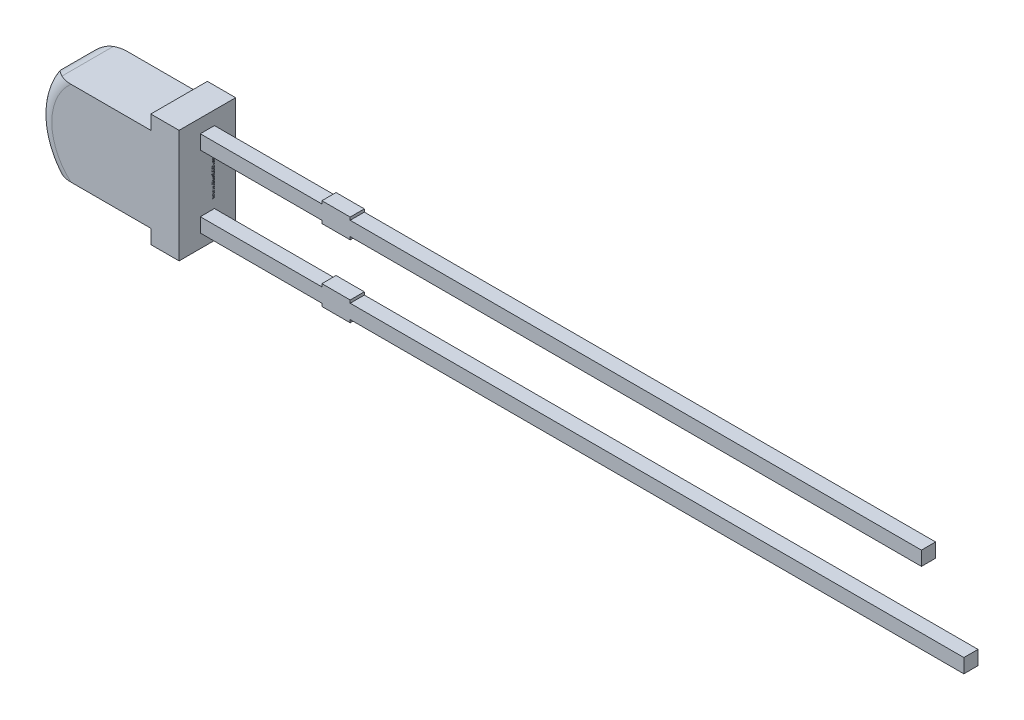
from build123d import *

# Parameters (mm, degrees)
SKETCH1_W          = 25.5
SKETCH1_H          = 0.5
SKETCH1_W_2        = 27
SKETCH1_W_3        = 1
SKETCH1_H_2        = 0.7
EXTRUDE2_DEPTH     = 0.25
EXTRUDE3_DEPTH     = 1
FILLET1_R          = 0.5
SKETCH2_W          = 0.026582278
SKETCH2_H          = 0.025316456
CUT_EXTRUDE1_DEPTH = 0.01


with BuildPart() as part:
    # Sketch1 → Extrude2 (new body, symmetric)
    with BuildSketch(Plane.XY):
        with Locations((15, 1.27)):
            Rectangle(SKETCH1_W, SKETCH1_H)
        with Locations((15.75, -1.27)):
            Rectangle(SKETCH1_W_2, SKETCH1_H)
        with Locations((7.05, 1.27)):
            Rectangle(SKETCH1_W_3, SKETCH1_H_2)
        with Locations((7.05, -1.27)):
            Rectangle(SKETCH1_W_3, SKETCH1_H_2)
    extrude(amount=EXTRUDE2_DEPTH, both=True)

    # Sketch1_5 → Extrude3 (add, symmetric)
    with BuildSketch(Plane.XY):
        with BuildLine():
            Line((1.25, 1.5), (-2.25, 1.5))
            ThreePointArc((-2.25, 1.5), (-2.75, 0), (-2.25, -1.5))
            Line((-2.25, -1.5), (1.25, -1.5))
            Line((1.25, -1.5), (1.25, -2))
            Line((1.25, -2), (2.25, -2))
            Line((2.25, -2), (2.25, 2))
            Line((2.25, 2), (1.25, 2))
            Line((1.25, 2), (1.25, 1.5))
        make_face()
    extrude(amount=EXTRUDE3_DEPTH, both=True)

    # Fillet1
    fillet1_edges = [part.edges().sort_by_distance(p)[0] for p in [
        (-2.25, -1.5, 0),
        (-2.75, 0, 1),
        (-2.25, 1.5, 0),
        (-2.75, 0, -1),
    ]]
    fillet(fillet1_edges, radius=FILLET1_R)

    # Sketch2 → Cut-Extrude1 (cut)
    with BuildSketch(Plane(origin=(2.25, 0, 0), x_dir=(0, 0, -1), z_dir=(1, 0, 0))):
        Polygon((0.175316456, -0.572151899), (0.25, -0.595609177), (0.25, -0.620352057), (0.199663766, -0.636768196), (0.25, -0.652294304), (0.25, -0.678026108), (0.175316456, -0.701265823), (0.175316456, -0.676087816), (0.226799842, -0.663093354), (0.175316456, -0.646677215), (0.175316456, -0.625178006), (0.226799842, -0.608860759), (0.175316456, -0.596044304), align=None)
        Polygon((0.175316456, -0.437974684), (0.25, -0.461431962), (0.25, -0.486174842), (0.199663766, -0.502590981), (0.25, -0.518117089), (0.25, -0.543848892), (0.175316456, -0.567088608), (0.175316456, -0.541910601), (0.226799842, -0.528916139), (0.175316456, -0.5125), (0.175316456, -0.491000791), (0.226799842, -0.474683544), (0.175316456, -0.461867089), align=None)
        Polygon((0.175316456, -0.303797468), (0.25, -0.327254747), (0.25, -0.351997627), (0.199663766, -0.368413766), (0.25, -0.383939873), (0.25, -0.409671677), (0.175316456, -0.432911392), (0.175316456, -0.407733386), (0.226799842, -0.394738924), (0.175316456, -0.378322785), (0.175316456, -0.356823576), (0.226799842, -0.340506329), (0.175316456, -0.327689873), align=None)
        with Locations((0.236708861, -0.275949367)):
            Rectangle(SKETCH2_W, SKETCH2_H)
        with BuildLine():
            add(Edge.make_bspline(
                [(0.218829114, -0.159493671), (0.220051236, -0.15953019), (0.222451075, -0.159601901), (0.225958932, -0.160211194), (0.229282615, -0.161206237), (0.232443853, -0.162572352), (0.23540828, -0.164381718), (0.238204295, -0.166563022), (0.240818493, -0.169150529), (0.24322702, -0.17210691), (0.245431684, -0.175388005), (0.24732279, -0.178990487), (0.248949325, -0.182859482), (0.2502805, -0.187013878), (0.251271415, -0.191459348), (0.25199469, -0.196177156), (0.252468209, -0.201170496), (0.252510149, -0.204594085), (0.252531646, -0.206348892)],
                knots=[0, 0, 0, 0, 0.907462679, 1.781953809, 2.635804048, 3.480274448, 4.332887508, 5.208817748, 6.109340518, 7.059474472, 8.037577805, 9.041105121, 10.077237313, 11.152245627, 12.27748741, 13.457227022, 14.696666784, 16, 16, 16, 16], degree=3))
            add(Edge.make_bspline(
                [(0.252531646, -0.206348892), (0.252504381, -0.208366877), (0.252451577, -0.212275063), (0.252066204, -0.217942631), (0.251378254, -0.223206098), (0.250421674, -0.228103845), (0.249218389, -0.232708145), (0.247927745, -0.23714149), (0.246463164, -0.241422782), (0.245363028, -0.244195874), (0.244818038, -0.24556962)],
                knots=[0, 0, 0, 0, 1.203182053, 2.33017619, 3.384818652, 4.366208123, 5.30340534, 6.221361684, 7.118890722, 8, 8, 8, 8], degree=3))
            Line((0.244818038, -0.24556962), (0.220886076, -0.24556962))
            Line((0.220886076, -0.24556962), (0.220886076, -0.242721519))
            add(Edge.make_bspline(
                [(0.220886076, -0.242721519), (0.221967039, -0.241355956), (0.224122618, -0.238632846), (0.226890972, -0.234205888), (0.229263982, -0.229546876), (0.231246605, -0.224708482), (0.232822219, -0.219807114), (0.233949125, -0.214938046), (0.234688489, -0.210169064), (0.23477005, -0.207010742), (0.234810127, -0.205458861)],
                knots=[0, 0, 0, 0, 1.030738938, 2.055426519, 3.085610749, 4.123842265, 5.148648843, 6.130724483, 7.081507926, 8, 8, 8, 8], degree=3))
            add(Edge.make_bspline(
                [(0.234810127, -0.205458861), (0.23480879, -0.205030118), (0.234805929, -0.204112212), (0.234685817, -0.202649556), (0.234555416, -0.201000033), (0.234361419, -0.199225642), (0.234127047, -0.197432474), (0.233785865, -0.195764575), (0.233413757, -0.194257809), (0.233046659, -0.193351105), (0.232871835, -0.192919304)],
                knots=[0, 0, 0, 0, 0.806557331, 1.726776592, 2.760222249, 3.920734434, 5.085813889, 6.161303184, 7.124353598, 8, 8, 8, 8], degree=3))
            add(Edge.make_bspline(
                [(0.232871835, -0.192919304), (0.232643282, -0.192440047), (0.232194127, -0.191498205), (0.231387464, -0.190196887), (0.230480651, -0.189041565), (0.229519264, -0.18798482), (0.228368617, -0.187098496), (0.226961414, -0.186481634), (0.225313428, -0.186135268), (0.22413807, -0.186096466), (0.223516614, -0.186075949)],
                knots=[0, 0, 0, 0, 1.025060442, 2.01446193, 2.949256246, 3.85908539, 4.768290539, 5.73153362, 6.800575992, 8, 8, 8, 8], degree=3))
            add(Edge.make_bspline(
                [(0.223516614, -0.186075949), (0.222971006, -0.186107814), (0.221898181, -0.186170468), (0.220362632, -0.186747374), (0.21895522, -0.187657973), (0.217681809, -0.188931946), (0.216563537, -0.190544736), (0.215540893, -0.192462318), (0.21471198, -0.194733369), (0.214273386, -0.196370181), (0.214042722, -0.197231013)],
                knots=[0, 0, 0, 0, 0.825786558, 1.623739628, 2.456775365, 3.355767579, 4.339087636, 5.42728423, 6.646958453, 8, 8, 8, 8], degree=3))
            add(Edge.make_bspline(
                [(0.214042722, -0.197231013), (0.213597012, -0.199200151), (0.212682272, -0.203241458), (0.211503178, -0.209382993), (0.210268525, -0.21551983), (0.209057108, -0.219470134), (0.20846519, -0.221400316)],
                knots=[0, 0, 0, 0, 0.976116373, 2.003306214, 3.02438349, 4, 4, 4, 4], degree=3))
            add(Edge.make_bspline(
                [(0.20846519, -0.221400316), (0.20811147, -0.222438472), (0.20742292, -0.224459338), (0.206270237, -0.227358497), (0.204965225, -0.23000186), (0.203642765, -0.232459004), (0.202164164, -0.234653033), (0.200623419, -0.236646745), (0.198984461, -0.238419051), (0.197227076, -0.239944561), (0.195392008, -0.241289007), (0.193443793, -0.242440034), (0.191382477, -0.243408151), (0.18921802, -0.244200582), (0.18694876, -0.244819413), (0.18457149, -0.245239559), (0.182088239, -0.245538255), (0.180393871, -0.245559023), (0.179529272, -0.24556962)],
                knots=[0, 0, 0, 0, 1.287139616, 2.505537848, 3.65787682, 4.745319116, 5.777517297, 6.75878323, 7.700384896, 8.605120322, 9.485712598, 10.366814604, 11.256335458, 12.154696155, 13.068779358, 14.012730507, 14.985940713, 16, 16, 16, 16], degree=3))
            add(Edge.make_bspline(
                [(0.179529272, -0.24556962), (0.178373126, -0.24553232), (0.176097851, -0.245458913), (0.172768828, -0.244857463), (0.16962001, -0.243830953), (0.166616854, -0.242444593), (0.16380259, -0.2406171), (0.161125104, -0.238424977), (0.158632608, -0.235814667), (0.156333971, -0.23282934), (0.154255166, -0.229542493), (0.152418458, -0.226008488), (0.150912011, -0.222229636), (0.14963078, -0.218249751), (0.148678384, -0.214030359), (0.147958807, -0.209593388), (0.147545806, -0.204919526), (0.147494531, -0.201728115), (0.147468354, -0.200098892)],
                knots=[0, 0, 0, 0, 0.894901293, 1.761149761, 2.608783409, 3.453876344, 4.314933854, 5.200038827, 6.12799933, 7.103249695, 8.113098521, 9.136064399, 10.182719798, 11.259667356, 12.370545059, 13.528828137, 14.738461593, 16, 16, 16, 16], degree=3))
            add(Edge.make_bspline(
                [(0.147468354, -0.200098892), (0.147490709, -0.198430234), (0.14753538, -0.195095747), (0.147910922, -0.190113874), (0.14847452, -0.185162543), (0.149281503, -0.180292383), (0.150290966, -0.17560825), (0.151380413, -0.171185772), (0.152620339, -0.167106707), (0.153574441, -0.164532994), (0.15403481, -0.163291139)],
                knots=[0, 0, 0, 0, 1.065384654, 2.128962885, 3.18847586, 4.246683315, 5.279600907, 6.247539799, 7.154412252, 8, 8, 8, 8], degree=3))
            Line((0.15403481, -0.163291139), (0.176582278, -0.163291139))
            Line((0.176582278, -0.163291139), (0.176582278, -0.166119462))
            add(Edge.make_bspline(
                [(0.176582278, -0.166119462), (0.175783133, -0.16719302), (0.174152259, -0.16938391), (0.172048226, -0.173032632), (0.170116523, -0.177006091), (0.168387193, -0.181273774), (0.166968062, -0.185747065), (0.165938626, -0.190324411), (0.165299605, -0.194951528), (0.165226459, -0.198053112), (0.165189873, -0.19960443)],
                knots=[0, 0, 0, 0, 0.892231706, 1.82084296, 2.804411717, 3.838445872, 4.890103822, 5.931567007, 6.965432763, 8, 8, 8, 8], degree=3))
            add(Edge.make_bspline(
                [(0.165189873, -0.19960443), (0.165214522, -0.200699669), (0.165263948, -0.202895847), (0.165607428, -0.206171246), (0.166287131, -0.209404419), (0.167098237, -0.211441491), (0.167503956, -0.212460443)],
                knots=[0, 0, 0, 0, 0.99896713, 2.003134239, 3.001159596, 4, 4, 4, 4], degree=3))
            add(Edge.make_bspline(
                [(0.167503956, -0.212460443), (0.16770515, -0.212894149), (0.168107405, -0.21376127), (0.168886797, -0.214969172), (0.169804037, -0.216088766), (0.170857301, -0.217093311), (0.172038369, -0.217917451), (0.17330104, -0.218558729), (0.174663973, -0.218918158), (0.175598013, -0.218964182), (0.176068038, -0.218987342)],
                knots=[0, 0, 0, 0, 1.005120364, 2.009570296, 3.014977851, 4.045438181, 5.061509448, 6.035608779, 7.011484765, 8, 8, 8, 8], degree=3))
            add(Edge.make_bspline(
                [(0.176068038, -0.218987342), (0.176705969, -0.218952547), (0.177924997, -0.218886059), (0.179638693, -0.218286061), (0.181101805, -0.217288392), (0.182094798, -0.216135293), (0.182793558, -0.215018314), (0.183298798, -0.213977797), (0.183812221, -0.212778346), (0.184301418, -0.211400897), (0.184795464, -0.209865762), (0.185270134, -0.20815684), (0.185719693, -0.206274232), (0.186005845, -0.204958342), (0.186155063, -0.204272152)],
                knots=[0, 0, 0, 0, 1.174343879, 2.244064321, 3.303704314, 4.407076671, 5.02483983, 5.732197225, 6.53898402, 7.431906431, 8.428480183, 9.514816237, 10.704066255, 12, 12, 12, 12], degree=3))
            add(Edge.make_bspline(
                [(0.186155063, -0.204272152), (0.186531164, -0.202439393), (0.187268822, -0.198844747), (0.188372053, -0.193441658), (0.189674916, -0.187946356), (0.190807308, -0.184269987), (0.191396361, -0.182357595)],
                knots=[0, 0, 0, 0, 0.995794372, 1.953081347, 2.935223864, 4, 4, 4, 4], degree=3))
            add(Edge.make_bspline(
                [(0.191396361, -0.182357595), (0.191715717, -0.181411104), (0.19234043, -0.179559616), (0.19342515, -0.176918101), (0.194607113, -0.174468933), (0.195830039, -0.172191063), (0.197191731, -0.170127593), (0.198609062, -0.168242758), (0.200115036, -0.166545595), (0.201730389, -0.165056465), (0.203441066, -0.163728463), (0.205290718, -0.162613457), (0.207239881, -0.161626842), (0.209320315, -0.160835225), (0.211531277, -0.160250746), (0.213858161, -0.159818068), (0.216303313, -0.159526859), (0.217977782, -0.159504857), (0.218829114, -0.159493671)],
                knots=[0, 0, 0, 0, 1.237247399, 2.420255609, 3.534416354, 4.605351393, 5.620193117, 6.593738998, 7.524982051, 8.426564095, 9.311945829, 10.20281032, 11.097671666, 12.01534975, 12.954438892, 13.926750701, 14.945921247, 16, 16, 16, 16], degree=3))
        make_face()
        with BuildLine():
            Line((0.25, -0.067088608), (0.25, -0.091139241))
            Line((0.25, -0.091139241), (0.242167722, -0.091139241))
            add(Edge.make_bspline(
                [(0.242167722, -0.091139241), (0.242976625, -0.092232381), (0.244536179, -0.094339941), (0.246611792, -0.097515206), (0.248404118, -0.100536174), (0.249910142, -0.103474602), (0.251137796, -0.106474005), (0.251949951, -0.109708164), (0.252454032, -0.113209191), (0.2525052, -0.115636342), (0.252531646, -0.116890823)],
                knots=[0, 0, 0, 0, 1.15097647, 2.219065785, 3.209751872, 4.123278731, 5.012494873, 5.946522673, 6.938654008, 8, 8, 8, 8], degree=3))
            add(Edge.make_bspline(
                [(0.252531646, -0.116890823), (0.252508688, -0.117907091), (0.252463982, -0.11988606), (0.2521224, -0.122764448), (0.2515735, -0.125466099), (0.250806818, -0.127996041), (0.249795405, -0.130347067), (0.248544706, -0.132504746), (0.247082839, -0.134491413), (0.245406585, -0.136295066), (0.243485438, -0.137885611), (0.241362738, -0.139272682), (0.239028085, -0.140448488), (0.236476722, -0.141390128), (0.233718277, -0.142145061), (0.230739071, -0.142669038), (0.227551931, -0.142989618), (0.225356803, -0.143021559), (0.224228639, -0.143037975)],
                knots=[0, 0, 0, 0, 1.108887696, 2.159324556, 3.158383213, 4.114277414, 5.039206009, 5.945047284, 6.830075132, 7.726032535, 8.625162295, 9.545152215, 10.487958828, 11.471559655, 12.508379831, 13.604991163, 14.769110247, 16, 16, 16, 16], degree=3))
            Line((0.224228639, -0.143037975), (0.175316456, -0.143037975))
            Line((0.175316456, -0.143037975), (0.175316456, -0.118987342))
            Line((0.175316456, -0.118987342), (0.21289557, -0.118987342))
            add(Edge.make_bspline(
                [(0.21289557, -0.118987342), (0.213812041, -0.118985706), (0.215566256, -0.118982576), (0.218072063, -0.118900237), (0.220340235, -0.118779336), (0.222382264, -0.118640631), (0.224229015, -0.118387615), (0.225895176, -0.118009906), (0.227414778, -0.11753908), (0.228321479, -0.117074761), (0.228757911, -0.116851266)],
                knots=[0, 0, 0, 0, 1.361401701, 2.605856924, 3.723918663, 4.735739235, 5.645738665, 6.489217889, 7.27279937, 8, 8, 8, 8], degree=3))
            add(Edge.make_bspline(
                [(0.228757911, -0.116851266), (0.22915655, -0.116621224), (0.229940239, -0.116168982), (0.23094752, -0.115249197), (0.231783912, -0.114173114), (0.232458611, -0.112903872), (0.232933771, -0.111407752), (0.233320951, -0.109682844), (0.233491169, -0.107690452), (0.23352591, -0.106283083), (0.233544304, -0.105537975)],
                knots=[0, 0, 0, 0, 0.848923305, 1.668910138, 2.502822694, 3.358979167, 4.311113223, 5.396624103, 6.621686681, 8, 8, 8, 8], degree=3))
            add(Edge.make_bspline(
                [(0.233544304, -0.105537975), (0.233524355, -0.104997054), (0.233483369, -0.103885683), (0.233294338, -0.102174294), (0.232890178, -0.100392654), (0.232246209, -0.097874301), (0.231059246, -0.094699608), (0.229701719, -0.092335231), (0.229015032, -0.091139241)],
                knots=[0, 0, 0, 0, 0.638098464, 1.31103257, 2.025970928, 2.789492669, 4.376004971, 6, 6, 6, 6], degree=3))
            Line((0.229015032, -0.091139241), (0.175316456, -0.091139241))
            Line((0.175316456, -0.091139241), (0.175316456, -0.067088608))
            Line((0.175316456, -0.067088608), (0.25, -0.067088608))
        make_face()
        with BuildLine():
            Line((0.25, 0.030379747), (0.25, 0.006329114))
            Line((0.25, 0.006329114), (0.212420886, 0.006329114))
            add(Edge.make_bspline(
                [(0.212420886, 0.006329114), (0.210890463, 0.006308303), (0.20783158, 0.006266709), (0.204074178, 0.005938503), (0.201227102, 0.005599031), (0.199397351, 0.005224273), (0.197849034, 0.004793931), (0.196963295, 0.004381503), (0.196558544, 0.004193038)],
                knots=[0, 0, 0, 0, 1.709225407, 3.416259723, 4.21101956, 4.910102269, 5.501957085, 6, 6, 6, 6], degree=3))
            add(Edge.make_bspline(
                [(0.196558544, 0.004193038), (0.196160412, 0.003948611), (0.195379818, 0.003469379), (0.194367934, 0.002531536), (0.19353119, 0.001434991), (0.192868341, 0.000155857), (0.192373933, -0.001325729), (0.192027651, -0.003045559), (0.191815428, -0.005025093), (0.191787128, -0.00643402), (0.191772152, -0.007179589)],
                knots=[0, 0, 0, 0, 0.860284341, 1.686708632, 2.528476982, 3.393563585, 4.332150703, 5.400907339, 6.624626855, 8, 8, 8, 8], degree=3))
            add(Edge.make_bspline(
                [(0.191772152, -0.007179589), (0.191832097, -0.008310545), (0.191954421, -0.010618379), (0.192623154, -0.013492792), (0.193476383, -0.015806428), (0.194242298, -0.017657215), (0.195199597, -0.019572829), (0.195926288, -0.020856385), (0.196301424, -0.021518987)],
                knots=[0, 0, 0, 0, 1.338233385, 2.730803257, 3.468495571, 4.255080394, 5.099229486, 6, 6, 6, 6], degree=3))
            Line((0.196301424, -0.021518987), (0.25, -0.021518987))
            Line((0.25, -0.021518987), (0.25, -0.04556962))
            Line((0.25, -0.04556962), (0.175316456, -0.04556962))
            Line((0.175316456, -0.04556962), (0.175316456, -0.021518987))
            Line((0.175316456, -0.021518987), (0.183148734, -0.021518987))
            add(Edge.make_bspline(
                [(0.183148734, -0.021518987), (0.182342296, -0.02046175), (0.180772517, -0.018403774), (0.178739108, -0.015227022), (0.176929251, -0.01215631), (0.175417117, -0.009101788), (0.174218517, -0.005977291), (0.173402914, -0.00270966), (0.172859966, 0.000707053), (0.172810154, 0.003043726), (0.17278481, 0.004232595)],
                knots=[0, 0, 0, 0, 1.126064518, 2.191951536, 3.19307265, 4.144813015, 5.076393104, 6.021983703, 6.993610568, 8, 8, 8, 8], degree=3))
            add(Edge.make_bspline(
                [(0.17278481, 0.004232595), (0.172810211, 0.00522886), (0.172859797, 0.007173746), (0.173169348, 0.010008596), (0.173720571, 0.012679702), (0.174516428, 0.015173087), (0.175507788, 0.01750877), (0.176711763, 0.019682454), (0.17817506, 0.021668259), (0.179834938, 0.023496579), (0.181726466, 0.025135042), (0.183854957, 0.026534404), (0.186197444, 0.027730277), (0.188746989, 0.028717595), (0.191525947, 0.029468634), (0.194519327, 0.029984818), (0.197730225, 0.030339095), (0.199946231, 0.030365925), (0.201087816, 0.030379747)],
                knots=[0, 0, 0, 0, 1.088244909, 2.124447647, 3.110254678, 4.062235362, 4.978491991, 5.877983887, 6.769571508, 7.666696544, 8.570415953, 9.495151274, 10.442024977, 11.43832337, 12.476026402, 13.580659577, 14.753665747, 16, 16, 16, 16], degree=3))
            Line((0.201087816, 0.030379747), (0.25, 0.030379747))
        make_face()
        Polygon((0.25, 0.125316456), (0.25, 0.053164557), (0.15, 0.053164557), (0.15, 0.078481013), (0.231012658, 0.078481013), (0.231012658, 0.125316456), align=None)
        Polygon((0.25, 0.212658228), (0.25, 0.140506329), (0.15, 0.140506329), (0.15, 0.212658228), (0.168987342, 0.212658228), (0.168987342, 0.165822785), (0.186708861, 0.165822785), (0.186708861, 0.208860759), (0.205696203, 0.208860759), (0.205696203, 0.165822785), (0.231012658, 0.165822785), (0.231012658, 0.212658228), align=None)
        with BuildLine():
            add(Edge.make_bspline(
                [(0.200098892, 0.329113924), (0.201246581, 0.329094609), (0.203519467, 0.329056357), (0.206884274, 0.328761165), (0.210149949, 0.32823514), (0.213334198, 0.327555959), (0.216413126, 0.326633453), (0.219420703, 0.325551739), (0.222326196, 0.324242093), (0.225127631, 0.322737241), (0.227799734, 0.321087768), (0.230319942, 0.319313019), (0.23270316, 0.31746724), (0.234898054, 0.315477927), (0.236940074, 0.313398746), (0.238830888, 0.311223217), (0.240534319, 0.308918153), (0.241557203, 0.30731099), (0.242068829, 0.30650712)],
                knots=[0, 0, 0, 0, 1.105570398, 2.18947457, 3.250358341, 4.290584537, 5.323553275, 6.344225964, 7.367641686, 8.3905646, 9.405808457, 10.390761353, 11.358902336, 12.307789878, 13.241960776, 14.165076779, 15.082208636, 16, 16, 16, 16], degree=3))
            add(Edge.make_bspline(
                [(0.242068829, 0.30650712), (0.24278118, 0.30526794), (0.244209516, 0.302783257), (0.245874907, 0.298798692), (0.247292943, 0.294671424), (0.248300154, 0.290304109), (0.249071633, 0.285666021), (0.249622116, 0.280667978), (0.249926212, 0.275267531), (0.249974844, 0.27153255), (0.25, 0.269600475)],
                knots=[0, 0, 0, 0, 0.896331627, 1.797236794, 2.705411718, 3.632841792, 4.606367508, 5.655603524, 6.787262262, 8, 8, 8, 8], degree=3))
            Line((0.25, 0.269600475), (0.25, 0.234177215))
            Line((0.25, 0.234177215), (0.15, 0.234177215))
            Line((0.15, 0.234177215), (0.15, 0.270609177))
            add(Edge.make_bspline(
                [(0.15, 0.270609177), (0.150016894, 0.272587865), (0.150049481, 0.276404509), (0.150462791, 0.281915405), (0.151071212, 0.287010921), (0.151967221, 0.291699732), (0.153075107, 0.296010589), (0.154467575, 0.299933416), (0.15595976, 0.303549763), (0.157234368, 0.305728284), (0.157852057, 0.306784019)],
                knots=[0, 0, 0, 0, 1.267100211, 2.444079055, 3.537724964, 4.552266402, 5.499704501, 6.385138932, 7.217420793, 8, 8, 8, 8], degree=3))
            add(Edge.make_bspline(
                [(0.157852057, 0.306784019), (0.158388598, 0.307634972), (0.159455511, 0.309327097), (0.161237363, 0.311728312), (0.16319344, 0.313957739), (0.165245259, 0.316086242), (0.167448147, 0.318066056), (0.16978685, 0.319909269), (0.172264957, 0.321613036), (0.174874377, 0.323171192), (0.177604617, 0.324591277), (0.180476962, 0.325783356), (0.183459835, 0.326822718), (0.186558775, 0.327668801), (0.189776165, 0.32832513), (0.193113645, 0.328771214), (0.196566833, 0.329054647), (0.198911627, 0.329093999), (0.200098892, 0.329113924)],
                knots=[0, 0, 0, 0, 0.964043478, 1.917004671, 2.862223898, 3.805158963, 4.749279098, 5.698713747, 6.657523689, 7.629652222, 8.610369353, 9.604453025, 10.607693792, 11.636365947, 12.681120053, 13.752669011, 14.862083412, 16, 16, 16, 16], degree=3))
        make_face()
        with BuildLine():
            add(Edge.make_bspline(
                [(0.199940665, 0.302531646), (0.198362809, 0.302485243), (0.195317141, 0.302395675), (0.190912939, 0.301732132), (0.186879674, 0.300552601), (0.18376317, 0.299223365), (0.181490155, 0.297884821), (0.179891824, 0.296757527), (0.178377641, 0.295507799), (0.176968796, 0.294117207), (0.175661761, 0.292582018), (0.17443285, 0.29092076), (0.173304205, 0.289120719), (0.172644199, 0.287847687), (0.172310127, 0.287203323)],
                knots=[0, 0, 0, 0, 1.694561208, 3.270940604, 4.767926833, 6.198032689, 6.896357436, 7.597727349, 8.296769799, 9.00280713, 9.720956486, 10.460265288, 11.220639329, 12, 12, 12, 12], degree=3))
            add(Edge.make_bspline(
                [(0.172310127, 0.287203323), (0.172003612, 0.286528388), (0.171396079, 0.285190619), (0.170661993, 0.283120344), (0.170099666, 0.281027643), (0.169627243, 0.278833415), (0.169350107, 0.276356655), (0.169137431, 0.273434164), (0.169000503, 0.269977491), (0.168991932, 0.267490895), (0.168987342, 0.266159019)],
                knots=[0, 0, 0, 0, 0.826913061, 1.638999358, 2.447478739, 3.243919028, 4.140906711, 5.225381046, 6.513851968, 8, 8, 8, 8], degree=3))
            Line((0.168987342, 0.266159019), (0.168987342, 0.259493671))
            Line((0.168987342, 0.259493671), (0.231012658, 0.259493671))
            Line((0.231012658, 0.259493671), (0.231012658, 0.266159019))
            add(Edge.make_bspline(
                [(0.231012658, 0.266159019), (0.231007616, 0.266917211), (0.230997882, 0.268380947), (0.23095873, 0.270497394), (0.230898581, 0.272462176), (0.230826183, 0.274269462), (0.230713532, 0.275919264), (0.230539542, 0.277406458), (0.230402845, 0.278743267), (0.230125721, 0.280315786), (0.229719474, 0.282170955), (0.229036403, 0.28433775), (0.228186805, 0.286478448), (0.227501729, 0.287866999), (0.227155854, 0.288568038)],
                knots=[0, 0, 0, 0, 1.186788252, 2.291168447, 3.31326867, 4.263560303, 5.122314491, 5.900668105, 6.60723418, 7.224768558, 8.398927205, 9.577205322, 10.776800932, 12, 12, 12, 12], degree=3))
            add(Edge.make_bspline(
                [(0.227155854, 0.288568038), (0.226812376, 0.28915175), (0.22613689, 0.290299682), (0.22503105, 0.291943861), (0.223795966, 0.293430472), (0.222513174, 0.294836999), (0.221121595, 0.29608816), (0.219678055, 0.297265459), (0.218103513, 0.2982507), (0.215914578, 0.29949957), (0.212887421, 0.300743145), (0.208915497, 0.301776761), (0.204556343, 0.302415553), (0.201518637, 0.302491957), (0.199940665, 0.302531646)],
                knots=[0, 0, 0, 0, 0.755184287, 1.485151634, 2.206180267, 2.908413556, 3.605665444, 4.291074465, 4.982332562, 5.673512475, 7.100235687, 8.614142391, 10.24117603, 12, 12, 12, 12], degree=3))
        make_face(mode=Mode.SUBTRACT)
        with Locations((0.236708861, 0.360759494)):
            Rectangle(SKETCH2_W, SKETCH2_H)
        with BuildLine():
            add(Edge.make_bspline(
                [(0.252531646, 0.435403481), (0.252509827, 0.433813372), (0.252467001, 0.430692242), (0.251990188, 0.426120851), (0.251272118, 0.421755856), (0.25025254, 0.417608916), (0.248903167, 0.413705632), (0.247268095, 0.410033248), (0.245268257, 0.406634041), (0.24368564, 0.404567057), (0.242899525, 0.403540348)],
                knots=[0, 0, 0, 0, 1.123640227, 2.2055255, 3.245221982, 4.248949655, 5.220213072, 6.160941522, 7.086505793, 8, 8, 8, 8], degree=3))
            add(Edge.make_bspline(
                [(0.242899525, 0.403540348), (0.242044692, 0.402588713), (0.240338332, 0.400689124), (0.237367788, 0.398221497), (0.234078815, 0.396103421), (0.230487163, 0.394291165), (0.226567277, 0.392859214), (0.222317383, 0.391866679), (0.217760053, 0.391239075), (0.214611849, 0.391173123), (0.212994462, 0.391139241)],
                knots=[0, 0, 0, 0, 0.916342154, 1.829140869, 2.758848968, 3.716597128, 4.708179637, 5.743612459, 6.840783343, 8, 8, 8, 8], degree=3))
            add(Edge.make_bspline(
                [(0.212994462, 0.391139241), (0.211291235, 0.391178001), (0.207990155, 0.391253124), (0.203217967, 0.391916883), (0.198800287, 0.392986496), (0.194748378, 0.394524054), (0.191055187, 0.396454496), (0.187683352, 0.398718989), (0.184640428, 0.401339514), (0.182894988, 0.403346653), (0.182021361, 0.404351266)],
                knots=[0, 0, 0, 0, 1.171797512, 2.271099083, 3.308930235, 4.294129479, 5.24602549, 6.17106565, 7.084581485, 8, 8, 8, 8], degree=3))
            add(Edge.make_bspline(
                [(0.182021361, 0.404351266), (0.181252707, 0.405377093), (0.179706115, 0.407441138), (0.177809395, 0.410840018), (0.176211429, 0.414456691), (0.174936469, 0.418279973), (0.173987224, 0.422262676), (0.173291458, 0.426332115), (0.172863315, 0.430476032), (0.172811104, 0.433266397), (0.17278481, 0.434671677)],
                knots=[0, 0, 0, 0, 0.952013349, 1.915525331, 2.885385798, 3.888123097, 4.906830296, 5.926067872, 6.955529031, 8, 8, 8, 8], degree=3))
            add(Edge.make_bspline(
                [(0.17278481, 0.434671677), (0.172801169, 0.43591849), (0.172833335, 0.438370146), (0.173164493, 0.441968871), (0.17366351, 0.445420869), (0.174407081, 0.448720159), (0.175329895, 0.451886357), (0.176354043, 0.454949807), (0.177493953, 0.457914044), (0.17837791, 0.459814797), (0.178817247, 0.460759494)],
                knots=[0, 0, 0, 0, 1.107572103, 2.177862056, 3.208491727, 4.204802822, 5.180069889, 6.137814326, 7.074472616, 8, 8, 8, 8], degree=3))
            Line((0.178817247, 0.460759494), (0.199367089, 0.460759494))
            Line((0.199367089, 0.460759494), (0.199367089, 0.45741693))
            add(Edge.make_bspline(
                [(0.199367089, 0.45741693), (0.198950197, 0.456917135), (0.19804326, 0.455829843), (0.196616375, 0.454048018), (0.19509511, 0.451893107), (0.194206443, 0.450248438), (0.193730222, 0.449367089)],
                knots=[0, 0, 0, 0, 0.792806788, 1.724728901, 2.780722718, 4, 4, 4, 4], degree=3))
            add(Edge.make_bspline(
                [(0.193730222, 0.449367089), (0.193290676, 0.448438429), (0.192386185, 0.446527444), (0.191521901, 0.443980324), (0.190985918, 0.441780001), (0.190723895, 0.439972051), (0.190536279, 0.43803794), (0.190516496, 0.436702768), (0.190506329, 0.436016614)],
                knots=[0, 0, 0, 0, 1.332411269, 2.741822805, 3.48048496, 4.268099981, 5.109965479, 6, 6, 6, 6], degree=3))
            add(Edge.make_bspline(
                [(0.190506329, 0.436016614), (0.19052567, 0.435250982), (0.190563151, 0.433767223), (0.190843064, 0.431606761), (0.191311637, 0.42958248), (0.191987879, 0.427693249), (0.192848185, 0.425938689), (0.193868345, 0.42430302), (0.195120334, 0.422827378), (0.196538767, 0.421485751), (0.198129091, 0.420298179), (0.19985563, 0.419271451), (0.201713509, 0.418388718), (0.20371142, 0.417686826), (0.205841282, 0.417129316), (0.208104092, 0.416739751), (0.21050369, 0.416497972), (0.212149985, 0.416470029), (0.212994462, 0.416455696)],
                knots=[0, 0, 0, 0, 1.087164589, 2.106874378, 3.088024391, 4.032801718, 4.949890679, 5.859058447, 6.763003849, 7.690312844, 8.626654282, 9.575690722, 10.539030902, 11.54301425, 12.578634972, 13.662366762, 14.800897888, 16, 16, 16, 16], degree=3))
            add(Edge.make_bspline(
                [(0.212994462, 0.416455696), (0.213858618, 0.416470471), (0.215537631, 0.416499177), (0.217979242, 0.416732691), (0.220260673, 0.417148582), (0.222385993, 0.41771983), (0.224352011, 0.418444178), (0.226149408, 0.419349295), (0.227806215, 0.420385652), (0.229268827, 0.42163021), (0.230585149, 0.422994093), (0.231721283, 0.424508985), (0.232669428, 0.426168224), (0.233473891, 0.427950405), (0.234052289, 0.429883445), (0.234488981, 0.431939982), (0.234777538, 0.434129537), (0.234799101, 0.435639891), (0.234810127, 0.436412184)],
                knots=[0, 0, 0, 0, 1.230336593, 2.390482092, 3.487897344, 4.52859895, 5.520747884, 6.465347575, 7.38981449, 8.296085817, 9.192433006, 10.084246191, 10.984321635, 11.908883871, 12.862027947, 13.850751296, 14.901019963, 16, 16, 16, 16], degree=3))
            add(Edge.make_bspline(
                [(0.234810127, 0.436412184), (0.234801272, 0.437137934), (0.234784009, 0.438552757), (0.234576566, 0.440613478), (0.234266178, 0.442563904), (0.233824546, 0.444396174), (0.233319347, 0.446107761), (0.23274215, 0.447669394), (0.232139505, 0.449082516), (0.231671691, 0.449943788), (0.231447785, 0.450356013)],
                knots=[0, 0, 0, 0, 1.201100869, 2.341500598, 3.425337164, 4.468451875, 5.459559168, 6.378110228, 7.223726512, 8, 8, 8, 8], degree=3))
            add(Edge.make_bspline(
                [(0.231447785, 0.450356013), (0.231020099, 0.451064369), (0.23019814, 0.452425742), (0.22877768, 0.454250861), (0.22737124, 0.455894986), (0.226414472, 0.456919091), (0.225949367, 0.45741693)],
                knots=[0, 0, 0, 0, 1.105932972, 2.12546697, 3.088749538, 4, 4, 4, 4], degree=3))
            Line((0.225949367, 0.45741693), (0.225949367, 0.460759494))
            Line((0.225949367, 0.460759494), (0.246657437, 0.460759494))
            add(Edge.make_bspline(
                [(0.246657437, 0.460759494), (0.247094979, 0.459814117), (0.247970168, 0.457923136), (0.249123319, 0.455008359), (0.250096198, 0.452015116), (0.250988545, 0.448963886), (0.25168674, 0.445794254), (0.25217597, 0.442476905), (0.252477709, 0.438995601), (0.252513421, 0.436617185), (0.252531646, 0.435403481)],
                knots=[0, 0, 0, 0, 0.952024047, 1.90427691, 2.862762905, 3.827874523, 4.80891974, 5.826446878, 6.890837857, 8, 8, 8, 8], degree=3))
        make_face()
        with BuildLine():
            add(Edge.make_bspline(
                [(0.212697785, 0.553164557), (0.214202617, 0.553139637), (0.217135938, 0.553091062), (0.221408758, 0.552554854), (0.225439199, 0.551731391), (0.229240037, 0.550598066), (0.232783083, 0.549080213), (0.236079037, 0.547237799), (0.239131219, 0.545064208), (0.241921446, 0.542573889), (0.244419638, 0.539772404), (0.246615831, 0.536698638), (0.248422879, 0.533328772), (0.249949428, 0.529720026), (0.251105529, 0.525830719), (0.25192348, 0.521671624), (0.252457811, 0.517254115), (0.252506624, 0.514215749), (0.252531646, 0.512658228)],
                knots=[0, 0, 0, 0, 1.120122129, 2.18341868, 3.201215738, 4.181270334, 5.131540819, 6.065757527, 6.988093576, 7.916512302, 8.844931028, 9.778115023, 10.722851943, 11.686686084, 12.691660064, 13.738321946, 14.84062285, 16, 16, 16, 16], degree=3))
            add(Edge.make_bspline(
                [(0.252531646, 0.512658228), (0.252506706, 0.51110068), (0.252458054, 0.508062261), (0.251922584, 0.503645127), (0.251109866, 0.499490907), (0.249940631, 0.495606256), (0.248428541, 0.491991945), (0.246615099, 0.488618118), (0.244419846, 0.485543936), (0.241921336, 0.482742733), (0.239131451, 0.480251696), (0.236078221, 0.478080692), (0.232788429, 0.476229753), (0.229231154, 0.47474936), (0.225443946, 0.473576829), (0.221407948, 0.472764049), (0.217136157, 0.472224732), (0.214202691, 0.472176594), (0.212697785, 0.472151899)],
                knots=[0, 0, 0, 0, 1.159424321, 2.261770074, 3.308474541, 4.308788811, 5.277191138, 6.221966496, 7.15518846, 8.08364496, 9.01210146, 9.934475036, 10.868729753, 11.817121636, 12.798654016, 13.816492484, 14.879832297, 16, 16, 16, 16], degree=3))
            add(Edge.make_bspline(
                [(0.212697785, 0.472151899), (0.211186352, 0.472177), (0.208233324, 0.472226044), (0.203934577, 0.472761711), (0.199873481, 0.473578673), (0.19606093, 0.474744205), (0.192498454, 0.476250482), (0.189192265, 0.478097428), (0.186145491, 0.480293183), (0.183355327, 0.482802618), (0.180860799, 0.485615383), (0.178682694, 0.488702882), (0.176873901, 0.492066422), (0.175346136, 0.495666774), (0.17421359, 0.499554435), (0.173395434, 0.503691062), (0.172857525, 0.508088545), (0.17280949, 0.511107271), (0.17278481, 0.512658228)],
                knots=[0, 0, 0, 0, 1.123883205, 2.195836198, 3.217400301, 4.202580581, 5.156396106, 6.089661422, 7.013912723, 7.944661364, 8.875797629, 9.805201257, 10.748976071, 11.711828658, 12.709674189, 13.755270167, 14.846705509, 16, 16, 16, 16], degree=3))
            add(Edge.make_bspline(
                [(0.17278481, 0.512658228), (0.172809522, 0.514228972), (0.172857636, 0.517287148), (0.173393975, 0.521730477), (0.174206501, 0.525904607), (0.175374571, 0.529802216), (0.17687784, 0.533426224), (0.178732787, 0.5367734), (0.180907137, 0.539858359), (0.183436965, 0.542626621), (0.186231919, 0.54511038), (0.189289599, 0.547272736), (0.192597175, 0.549108213), (0.196159051, 0.550583955), (0.199951683, 0.551758158), (0.203986109, 0.552578569), (0.208261016, 0.553084721), (0.211193159, 0.553137483), (0.212697785, 0.553164557)],
                knots=[0, 0, 0, 0, 1.167473013, 2.273023816, 3.322954552, 4.326451713, 5.293391623, 6.234801871, 7.166614545, 8.093305908, 9.017100806, 9.942078766, 10.872536262, 11.824015763, 12.804065898, 13.820367293, 14.881523901, 16, 16, 16, 16], degree=3))
        make_face()
        with BuildLine():
            add(Edge.make_bspline(
                [(0.231190665, 0.523457278), (0.230690401, 0.523811854), (0.229672304, 0.524533458), (0.227972807, 0.525414912), (0.226131019, 0.526165223), (0.224106261, 0.526786059), (0.221815916, 0.527300861), (0.219164963, 0.52759945), (0.216130213, 0.527833002), (0.213977385, 0.52784287), (0.212836234, 0.527848101)],
                knots=[0, 0, 0, 0, 0.765135464, 1.557141201, 2.384449913, 3.246599353, 4.1996426, 5.311961702, 6.575150963, 8, 8, 8, 8], degree=3))
            add(Edge.make_bspline(
                [(0.212836234, 0.527848101), (0.21176136, 0.527830368), (0.209702019, 0.527796392), (0.206742154, 0.527610608), (0.204052656, 0.527259147), (0.201627948, 0.526765631), (0.199455878, 0.526158041), (0.19752355, 0.525423239), (0.195809595, 0.524589801), (0.194804474, 0.523904047), (0.194323576, 0.523575949)],
                knots=[0, 0, 0, 0, 1.337015307, 2.56157572, 3.686511827, 4.707709802, 5.636963675, 6.488272502, 7.276717686, 8, 8, 8, 8], degree=3))
            add(Edge.make_bspline(
                [(0.194323576, 0.523575949), (0.193885931, 0.523237287), (0.193031189, 0.522575862), (0.191924868, 0.521419361), (0.191055061, 0.52013186), (0.190350328, 0.518766917), (0.189874232, 0.517311235), (0.189508645, 0.515811038), (0.189290222, 0.51425344), (0.18925717, 0.513192902), (0.189240506, 0.512658228)],
                knots=[0, 0, 0, 0, 1.058303018, 2.066917725, 3.046948061, 4.023234392, 4.996907708, 5.970172105, 6.976653347, 8, 8, 8, 8], degree=3))
            add(Edge.make_bspline(
                [(0.189240506, 0.512658228), (0.189251536, 0.512130325), (0.18927311, 0.511097766), (0.189451627, 0.509594689), (0.189751626, 0.508179036), (0.190155811, 0.50683387), (0.190767188, 0.505548722), (0.191616005, 0.504317445), (0.192692585, 0.503102058), (0.19354292, 0.50236373), (0.193987342, 0.501977848)],
                knots=[0, 0, 0, 0, 1.04189444, 2.037910168, 2.982338511, 3.896140384, 4.804271323, 5.778885192, 6.839150358, 8, 8, 8, 8], degree=3))
            add(Edge.make_bspline(
                [(0.193987342, 0.501977848), (0.194461009, 0.501642414), (0.195455117, 0.500938424), (0.197175487, 0.500089235), (0.199120978, 0.499319936), (0.201312114, 0.498640648), (0.203779654, 0.498109463), (0.206538267, 0.497751274), (0.209588201, 0.497506594), (0.211721508, 0.497481478), (0.212836234, 0.497468354)],
                knots=[0, 0, 0, 0, 0.70629823, 1.482341141, 2.329662943, 3.254583898, 4.274063958, 5.401087491, 6.641978366, 8, 8, 8, 8], degree=3))
            add(Edge.make_bspline(
                [(0.212836234, 0.497468354), (0.213838969, 0.497474304), (0.215781093, 0.497485828), (0.218583477, 0.497727894), (0.221191744, 0.498015163), (0.223580395, 0.498500249), (0.225769559, 0.499078592), (0.227727699, 0.499811255), (0.229475433, 0.500650609), (0.230499113, 0.501345833), (0.23099288, 0.501681171)],
                knots=[0, 0, 0, 0, 1.270931856, 2.461574991, 3.564842381, 4.596079713, 5.549239655, 6.432768418, 7.244053423, 8, 8, 8, 8], degree=3))
            add(Edge.make_bspline(
                [(0.23099288, 0.501681171), (0.231409784, 0.502021462), (0.232231738, 0.502692369), (0.233306021, 0.503841178), (0.234185641, 0.50510292), (0.234882345, 0.506463378), (0.235415263, 0.507926821), (0.23581568, 0.509481783), (0.236026743, 0.511142692), (0.236059272, 0.512275314), (0.236075949, 0.512856013)],
                knots=[0, 0, 0, 0, 1.011235752, 1.993715204, 2.946409587, 3.894575777, 4.859533504, 5.869856863, 6.907869553, 8, 8, 8, 8], degree=3))
            add(Edge.make_bspline(
                [(0.236075949, 0.512856013), (0.236025396, 0.513864117), (0.235925071, 0.515864737), (0.235183405, 0.518276041), (0.234325663, 0.520072218), (0.233490999, 0.521339493), (0.232426404, 0.522470719), (0.231607882, 0.52312419), (0.231190665, 0.523457278)],
                knots=[0, 0, 0, 0, 1.494110474, 2.96511767, 3.704956058, 4.446088323, 5.207938169, 6, 6, 6, 6], degree=3))
        make_face(mode=Mode.SUBTRACT)
        with BuildLine():
            Line((0.196301424, 0.644303797), (0.25, 0.644303797))
            Line((0.25, 0.644303797), (0.25, 0.620253165))
            Line((0.25, 0.620253165), (0.212143987, 0.620253165))
            add(Edge.make_bspline(
                [(0.212143987, 0.620253165), (0.211253988, 0.620246898), (0.209546423, 0.620234875), (0.207086093, 0.620212363), (0.204838751, 0.620096991), (0.202791415, 0.620000439), (0.20093503, 0.619801755), (0.199255321, 0.619524083), (0.197752325, 0.619095228), (0.19685121, 0.618687802), (0.196420095, 0.61849288)],
                knots=[0, 0, 0, 0, 1.33997484, 2.570892857, 3.703483919, 4.727540125, 5.655929516, 6.512630168, 7.288405602, 8, 8, 8, 8], degree=3))
            add(Edge.make_bspline(
                [(0.196420095, 0.61849288), (0.196034885, 0.618282873), (0.195271303, 0.617866586), (0.194301152, 0.616999731), (0.193497118, 0.615984414), (0.192821546, 0.614820738), (0.1923615, 0.613425719), (0.192000355, 0.611817719), (0.191823871, 0.609952288), (0.191790041, 0.608630238), (0.191772152, 0.607931171)],
                knots=[0, 0, 0, 0, 0.859137151, 1.703023591, 2.531884144, 3.395689496, 4.329139829, 5.403231912, 6.626892925, 8, 8, 8, 8], degree=3))
            add(Edge.make_bspline(
                [(0.191772152, 0.607931171), (0.191795018, 0.607343691), (0.191840957, 0.606163433), (0.192093687, 0.604403162), (0.192557472, 0.602668945), (0.193402753, 0.600450118), (0.194647862, 0.597858933), (0.195763692, 0.595887005), (0.196301424, 0.594936709)],
                knots=[0, 0, 0, 0, 0.759205818, 1.525260036, 2.291692926, 3.073215079, 4.589547174, 6, 6, 6, 6], degree=3))
            Line((0.196301424, 0.594936709), (0.25, 0.594936709))
            Line((0.25, 0.594936709), (0.25, 0.570886076))
            Line((0.25, 0.570886076), (0.175316456, 0.570886076))
            Line((0.175316456, 0.570886076), (0.175316456, 0.594936709))
            Line((0.175316456, 0.594936709), (0.183148734, 0.594936709))
            add(Edge.make_bspline(
                [(0.183148734, 0.594936709), (0.182366873, 0.595957498), (0.180848815, 0.597939458), (0.17880616, 0.60095963), (0.177026096, 0.603901326), (0.175475652, 0.606795115), (0.174264938, 0.609757591), (0.173415278, 0.612850643), (0.172886216, 0.616094734), (0.172819023, 0.618312831), (0.17278481, 0.619442247)],
                knots=[0, 0, 0, 0, 1.135996309, 2.205644619, 3.219721285, 4.173434518, 5.103784725, 6.040859173, 7.002439823, 8, 8, 8, 8], degree=3))
            add(Edge.make_bspline(
                [(0.17278481, 0.619442247), (0.172816742, 0.620645387), (0.172879151, 0.622996841), (0.173545796, 0.626410207), (0.174559074, 0.629618041), (0.176014514, 0.632594214), (0.177887184, 0.635295415), (0.180138035, 0.637716747), (0.182807568, 0.639805169), (0.184812476, 0.640896925), (0.185838608, 0.641455696)],
                knots=[0, 0, 0, 0, 1.065874838, 2.083178459, 3.072535385, 4.042784727, 5.009538681, 5.977671113, 6.9649521, 8, 8, 8, 8], degree=3))
            add(Edge.make_bspline(
                [(0.185838608, 0.641455696), (0.184861643, 0.642637781), (0.182957727, 0.644941436), (0.180415105, 0.648495052), (0.178160548, 0.651974132), (0.176251723, 0.655414652), (0.174701169, 0.658815096), (0.173607182, 0.662197602), (0.172914818, 0.665544031), (0.172827729, 0.667771115), (0.17278481, 0.668868671)],
                knots=[0, 0, 0, 0, 1.188147474, 2.315470194, 3.384102413, 4.399459064, 5.362307068, 6.27522031, 7.149990929, 8, 8, 8, 8], degree=3))
            add(Edge.make_bspline(
                [(0.17278481, 0.668868671), (0.172808216, 0.669851914), (0.172853758, 0.671765043), (0.17318862, 0.674547694), (0.173760889, 0.677143547), (0.174547938, 0.679562978), (0.175585482, 0.68178885), (0.176835136, 0.683847567), (0.178325311, 0.685714029), (0.180045865, 0.687385842), (0.181972299, 0.6888796), (0.184117748, 0.690156778), (0.186453449, 0.691257557), (0.18899463, 0.692139703), (0.191734924, 0.692830189), (0.194678399, 0.693318848), (0.197818169, 0.693617464), (0.19997954, 0.693652778), (0.201087816, 0.693670886)],
                knots=[0, 0, 0, 0, 1.099342309, 2.139026208, 3.128160419, 4.067670031, 4.978005126, 5.868115408, 6.754646573, 7.640901823, 8.544826239, 9.474098828, 10.427191309, 11.427444495, 12.477013521, 13.583550168, 14.760928455, 16, 16, 16, 16], degree=3))
            Line((0.201087816, 0.693670886), (0.25, 0.693670886))
            Line((0.25, 0.693670886), (0.25, 0.669620253))
            Line((0.25, 0.669620253), (0.212143987, 0.669620253))
            add(Edge.make_bspline(
                [(0.212143987, 0.669620253), (0.211247369, 0.66961458), (0.20952657, 0.669603692), (0.207053653, 0.669573443), (0.204799176, 0.669484896), (0.202752824, 0.669403176), (0.200906788, 0.669237293), (0.199242641, 0.668945325), (0.197756706, 0.668518143), (0.196851807, 0.668126113), (0.196420095, 0.667939082)],
                knots=[0, 0, 0, 0, 1.350818449, 2.592504867, 3.725474742, 4.749698069, 5.67770978, 6.515438232, 7.29174147, 8, 8, 8, 8], degree=3))
            add(Edge.make_bspline(
                [(0.196420095, 0.667939082), (0.196035243, 0.667735627), (0.195273291, 0.667332814), (0.194296063, 0.666484844), (0.193492089, 0.665466142), (0.192822191, 0.664285498), (0.192361607, 0.66287167), (0.192000589, 0.661243893), (0.191823225, 0.659352338), (0.191789862, 0.658010521), (0.191772152, 0.657298259)],
                knots=[0, 0, 0, 0, 0.846249014, 1.675452091, 2.498159353, 3.366742707, 4.305389074, 5.384053484, 6.611407474, 8, 8, 8, 8], degree=3))
            add(Edge.make_bspline(
                [(0.191772152, 0.657298259), (0.191820295, 0.656297521), (0.191917446, 0.654278103), (0.192624382, 0.651791697), (0.193446012, 0.649768641), (0.194253109, 0.648089209), (0.195188123, 0.646230911), (0.195918858, 0.644966017), (0.196301424, 0.644303797)],
                knots=[0, 0, 0, 0, 1.291138255, 2.605424171, 3.312558404, 4.112852492, 5.012008078, 6, 6, 6, 6], degree=3))
        make_face()
    extrude(amount=-CUT_EXTRUDE1_DEPTH, mode=Mode.SUBTRACT)


solid = part.part
